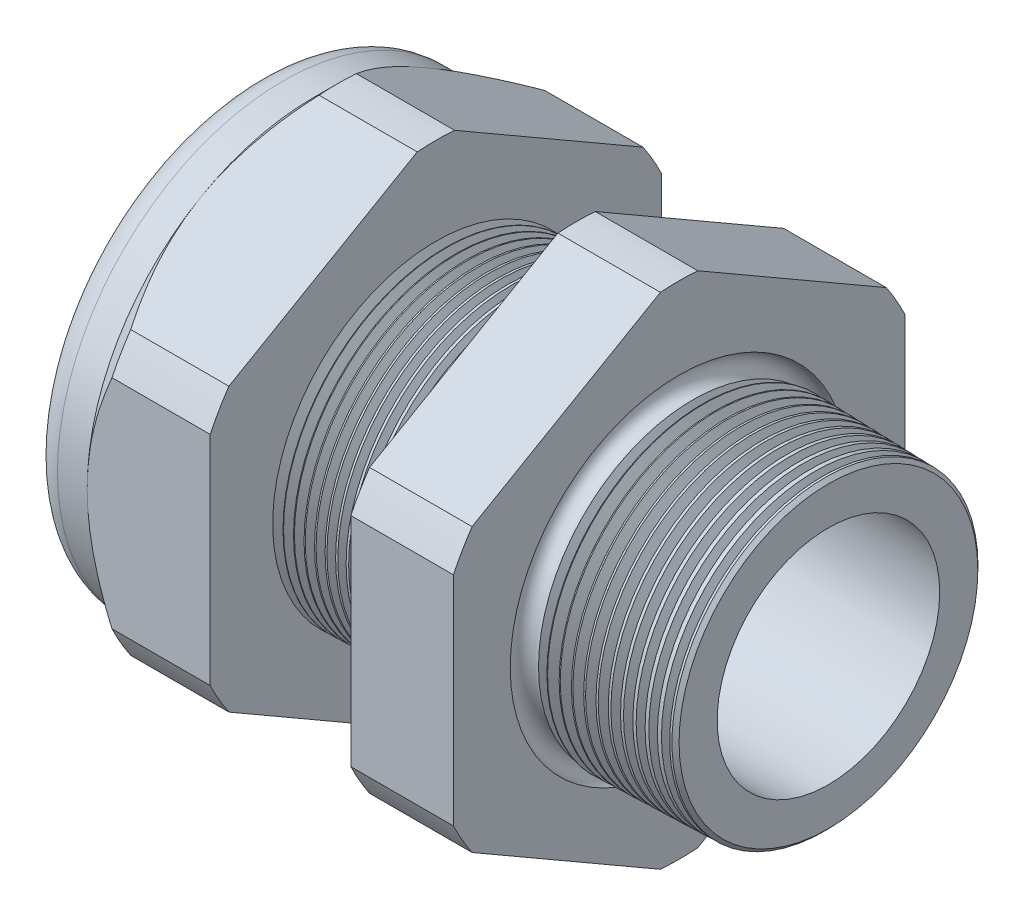
from build123d import *

# Parameters (mm, degrees)
SKETCH12_OUTSIDE_W = 88.514
SKETCH12_OUTSIDE_H = 88.514
CUT_EXTRUDE2_DEPTH = 38.71
FILLET4_R          = 2.032
SKETCH19_OUTSIDE_W = 55.962
SKETCH19_OUTSIDE_H = 59.594
SKETCH19_OUTSIDE_R = 16.51
CUT_EXTRUDE3_DEPTH = 3.99796
CUT_EXTRUDE3_DRAFT = -45
CHAMFER1_SIZE      = 0.260919487
CHAMFER1_SIZE2     = 0.254
SKETCH21_R         = 9.017
PLUG_DEPTH         = 8.89
SKETCH22_R         = 8.763
CUT_EXTRUDE4_DEPTH = 0.508
SKETCH27_R         = 3.937
PLUGHOLES_DEPTH    = 42.402
CIRPATTERN1_COUNT  = 2
LPATTERN1_COUNT    = 14
LPATTERN1_PITCH    = 0.762
LPATTERN2_COUNT    = 12
LPATTERN2_PITCH    = 0.889
SKETCH32_R         = 0.889


with BuildPart() as part:
    # Sketch10 → Revolve2 (revolve)
    with BuildSketch(Plane.XY, mode=Mode.PRIVATE) as revolve2_sk:
        Polygon((-38.862, 9.017), (-25.662, 9.017), (3.048, 8.138202192), (3.048, 11.186202192), (-7.874, 11.472204827), (-7.874, 33.02), (-15.374, 33.02), (-15.374, 11.668599239), (-25.662, 11.938), (-25.662, 33.02), (-34.662, 33.02), (-34.662, 16.51), (-38.862, 16.51), align=None)
    revolve(revolve2_sk.sketch.rotate(Axis((0, 0, 0), (-1, 0, 0)), 90), axis=Axis((0, 0, 0), (-1, 0, 0)))  # turned: the seam where the file's is

    # Sketch12 outside → Cut-Extrude2 (cut, through all)
    with BuildSketch(Plane.ZY.offset(34.662)):
        Rectangle(SKETCH12_OUTSIDE_W, SKETCH12_OUTSIDE_H)
        with BuildLine():
            Line((-1.366648898, 18.27507078), (-15.143351102, 10.321088053))
            ThreePointArc((-15.143351102, 10.321088053), (-15.870868152, 9.16305), (-16.51, 7.953982726))
            Line((-16.51, 7.953982726), (-16.51, -7.953982726))
            ThreePointArc((-16.51, -7.953982726), (-15.870868152, -9.16305), (-15.143351102, -10.321088053))
            Line((-15.143351102, -10.321088053), (-1.366648898, -18.27507078))
            ThreePointArc((-1.366648898, -18.27507078), (0, -18.3261), (1.366648898, -18.27507078))
            Line((1.366648898, -18.27507078), (15.143351102, -10.321088053))
            ThreePointArc((15.143351102, -10.321088053), (15.870868152, -9.16305), (16.51, -7.953982726))
            Line((16.51, -7.953982726), (16.51, 7.953982726))
            ThreePointArc((16.51, 7.953982726), (15.870868152, 9.16305), (15.143351102, 10.321088053))
            Line((15.143351102, 10.321088053), (1.366648898, 18.27507078))
            ThreePointArc((1.366648898, 18.27507078), (0, 18.3261), (-1.366648898, 18.27507078))
        make_face(mode=Mode.SUBTRACT)
    extrude(amount=-CUT_EXTRUDE2_DEPTH, mode=Mode.SUBTRACT)

    # Fillet4
    fillet4_edges = [part.edges().sort_by_distance(p)[0] for p in [
        (-38.862, 0, 16.51),
    ]]
    fillet(fillet4_edges, radius=FILLET4_R)


with BuildPart() as cut_extrude3_tool:
    # Sketch19 outside → Cut-Extrude3 (with draft: the straight prism first)
    with BuildSketch(Plane.ZY.offset(34.662)):
        Rectangle(SKETCH19_OUTSIDE_W, SKETCH19_OUTSIDE_H)
        Circle(SKETCH19_OUTSIDE_R, mode=Mode.SUBTRACT)
    extrude(amount=-CUT_EXTRUDE3_DEPTH)
    # Cut-Extrude3: the draft: its side faces are tilted about the plane it starts from
    cut_extrude3_sides = [cut_extrude3_tool.faces().sort_by_distance(p)[0] for p in [
        (-32.66302, -29.797, 0),
        (-32.66302, 0, 27.981),
        (-32.66302, 29.797, 0),
        (-32.66302, 0, -27.981),
        (-32.66302, 0, -16.51),
    ]]
    draft(cut_extrude3_sides, Plane.ZY.offset(34.662), CUT_EXTRUDE3_DRAFT)


with BuildPart() as part_1:
    add(part.part)

    # Cut-Extrude3: cut by cut_extrude3_tool
    add(cut_extrude3_tool.part, mode=Mode.SUBTRACT)

    # Chamfer1
    chamfer1_edges = [part_1.edges().sort_by_distance(p)[0] for p in [
        (3.048, 0, 11.186202192),
    ]]
    chamfer1_side = [part_1.faces().sort_by_distance(p)[0] for p in [
        (3.048, 0, 8.454595769),
    ]]
    chamfer(chamfer1_edges, length=CHAMFER1_SIZE, length2=CHAMFER1_SIZE2, reference=chamfer1_side[0])

    # Sketch29 → Cut-Revolve1 (revolve, cut)
    with BuildSketch(Plane.XY, mode=Mode.PRIVATE) as cut_revolve1_sk:
        Polygon((-25.662, 11.938), (-24.929016419, 11.918806149), (-25.312130572, 11.293620673), align=None)
    cut_revolve1 = revolve(cut_revolve1_sk.sketch.rotate(Axis((0, 0, 0), (-1, 0, 0)), 90), axis=Axis((0, 0, 0), (-1, 0, 0)), mode=Mode.SUBTRACT)  # turned: the seam where the file's is

    # LPattern1: Cut-Revolve1 ×14
    with Locations(*[(i * LPATTERN1_PITCH, 0, 0) for i in range(1, LPATTERN1_COUNT)]):
        add(cut_revolve1, mode=Mode.SUBTRACT)

    # Sketch30 → Cut-Revolve2 (revolve, cut)
    with BuildSketch(Plane.XY, mode=Mode.PRIVATE) as cut_revolve2_sk:
        Polygon((-7.874, 11.472204827), (-6.994419703, 11.449172206), (-7.454156686, 10.698949635), align=None)
    cut_revolve2 = revolve(cut_revolve2_sk.sketch.rotate(Axis((0, 0, 0), (-1, 0, 0)), 270), axis=Axis((0, 0, 0), (-1, 0, 0)), mode=Mode.SUBTRACT)  # turned: the seam where the file's is

    # LPattern2: Cut-Revolve2 ×12
    with Locations(*[(i * LPATTERN2_PITCH, 0, 0) for i in range(1, LPATTERN2_COUNT)]):
        add(cut_revolve2, mode=Mode.SUBTRACT)

    # Sketch32 → Cut-Revolve3 (revolve, cut)
    with BuildSketch(Plane.XY, mode=Mode.PRIVATE) as cut_revolve3_sk:
        with Locations((-7.747, 11.472204827)):
            Circle(SKETCH32_R)
    revolve(cut_revolve3_sk.sketch.rotate(Axis((0, 0, 0), (-1, 0, 0)), 270), axis=Axis((0, 0, 0), (-1, 0, 0)), mode=Mode.SUBTRACT)  # turned: the seam where the file's is


with BuildPart() as body_2:
    # Sketch21 → plug (new body)
    with BuildSketch(Plane.ZY.offset(38.862)):
        Circle(SKETCH21_R)
    extrude(amount=-PLUG_DEPTH)

    # Sketch22 → Cut-Extrude4 (cut)
    with BuildSketch(Plane.ZY.offset(38.862)):
        Circle(SKETCH22_R)
    extrude(amount=-CUT_EXTRUDE4_DEPTH, mode=Mode.SUBTRACT)

    # Sketch27 → plugholes (cut, through all)
    with BuildSketch(Plane.ZY.offset(38.354)):
        with Locations((-4.810252, 0)):
            Circle(SKETCH27_R)
    plugholes = extrude(amount=-PLUGHOLES_DEPTH, mode=Mode.SUBTRACT)

    # CirPattern1: plugholes ×2 about axis
    cirpattern1_axis = Axis((0, 0, 0), (1, 0, 0))
    for i in range(1, CIRPATTERN1_COUNT):
        add(plugholes.rotate(cirpattern1_axis, i * 360 / CIRPATTERN1_COUNT), mode=Mode.SUBTRACT)


solid = Compound([part_1.part, body_2.part])
